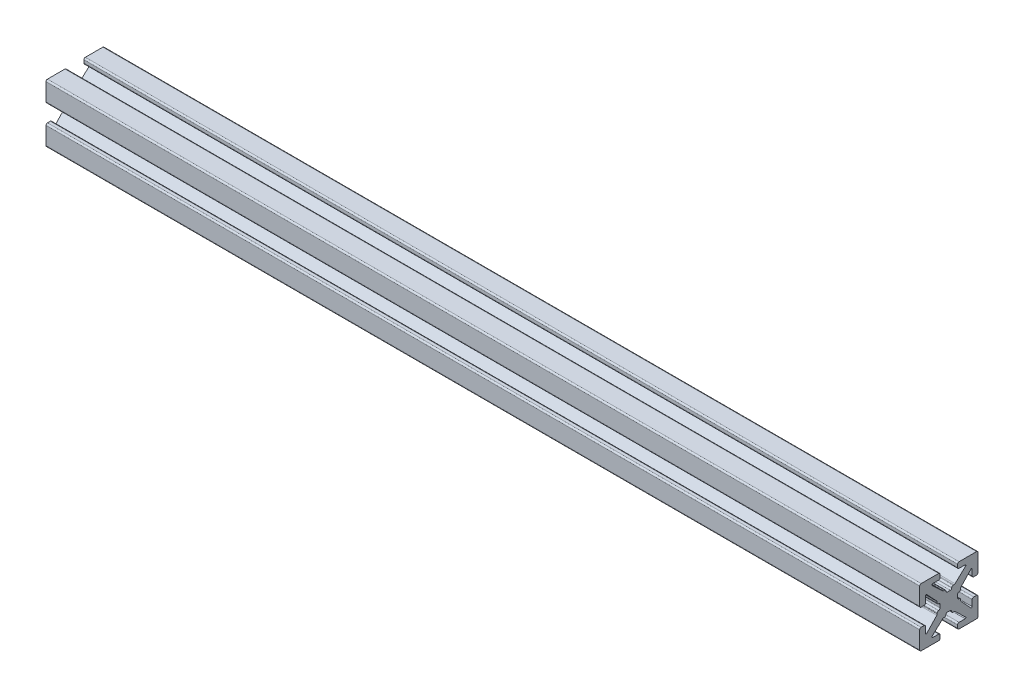
from build123d import *

# Parameters (mm, degrees)
BOSS_EXTRU_1_DEPTH = 150


with BuildPart() as part:
    # Sketch1 → Boss.-Extru.1 (new body)
    with BuildSketch(Plane(origin=(0, 0, 0), x_dir=(0, 0, -1), z_dir=(1, 0, 0))):
        with BuildLine():
            Line((-0.2413, 1.4986), (0.2413, 1.4986))
            ThreePointArc((0.2413, 1.4986), (0.420905122, 1.572994878), (0.4953, 1.7526))
            ThreePointArc((0.4953, 1.7526), (0.569694878, 1.932205122), (0.7493, 2.0066))
            Line((0.7493, 2.0066), (0.889923986, 2.0066))
            ThreePointArc((0.889923986, 2.0066), (0.983516259, 2.024471886), (1.063937899, 2.075572548))
            Line((1.063937899, 2.075572548), (2.890793, 3.793686274))
            ThreePointArc((2.890793, 3.793686274), (2.921850101, 3.932996137), (2.803786044, 4.0132))
            Line((2.803786044, 4.0132), (1.7526, 4.0132))
            ThreePointArc((1.7526, 4.0132), (1.572994878, 4.087594878), (1.4986, 4.2672))
            Line((1.4986, 4.2672), (1.4986, 4.7498))
            ThreePointArc((1.4986, 4.7498), (1.572994878, 4.929405122), (1.7526, 5.0038))
            Line((1.7526, 5.0038), (4.7498, 5.0038))
            ThreePointArc((4.7498, 5.0038), (4.929405122, 4.929405122), (5.0038, 4.7498))
            Line((5.0038, 4.7498), (5.0038, 1.7526))
            ThreePointArc((5.0038, 1.7526), (4.929405122, 1.572994878), (4.7498, 1.4986))
            Line((4.7498, 1.4986), (4.2672, 1.4986))
            ThreePointArc((4.2672, 1.4986), (4.087594878, 1.572994878), (4.0132, 1.7526))
            Line((4.0132, 1.7526), (4.0132, 2.803786044))
            ThreePointArc((4.0132, 2.803786044), (3.932996137, 2.921850101), (3.793686274, 2.890793))
            Line((3.793686274, 2.890793), (2.075572548, 1.063937899))
            ThreePointArc((2.075572548, 1.063937899), (2.024471886, 0.983516259), (2.0066, 0.889923986))
            Line((2.0066, 0.889923986), (2.0066, 0.7493))
            ThreePointArc((2.0066, 0.7493), (1.932205122, 0.569694878), (1.7526, 0.4953))
            ThreePointArc((1.7526, 0.4953), (1.572994878, 0.420905122), (1.4986, 0.2413))
            Line((1.4986, 0.2413), (1.4986, -0.2413))
            ThreePointArc((1.4986, -0.2413), (1.572994878, -0.420905122), (1.7526, -0.4953))
            ThreePointArc((1.7526, -0.4953), (1.932205122, -0.569694878), (2.0066, -0.7493))
            Line((2.0066, -0.7493), (2.0066, -0.889923986))
            ThreePointArc((2.0066, -0.889923986), (2.024471886, -0.983516259), (2.075572548, -1.063937899))
            Line((2.075572548, -1.063937899), (3.793686274, -2.890793))
            ThreePointArc((3.793686274, -2.890793), (3.932996137, -2.921850101), (4.0132, -2.803786044))
            Line((4.0132, -2.803786044), (4.0132, -1.7526))
            ThreePointArc((4.0132, -1.7526), (4.087594878, -1.572994878), (4.2672, -1.4986))
            Line((4.2672, -1.4986), (4.7498, -1.4986))
            ThreePointArc((4.7498, -1.4986), (4.929405122, -1.572994878), (5.0038, -1.7526))
            Line((5.0038, -1.7526), (5.0038, -4.7498))
            ThreePointArc((5.0038, -4.7498), (4.929405122, -4.929405122), (4.7498, -5.0038))
            Line((4.7498, -5.0038), (1.7526, -5.0038))
            ThreePointArc((1.7526, -5.0038), (1.572994878, -4.929405122), (1.4986, -4.7498))
            Line((1.4986, -4.7498), (1.4986, -4.2672))
            ThreePointArc((1.4986, -4.2672), (1.572994878, -4.087594878), (1.7526, -4.0132))
            Line((1.7526, -4.0132), (2.803786044, -4.0132))
            ThreePointArc((2.803786044, -4.0132), (2.921850101, -3.932996137), (2.890793, -3.793686274))
            Line((2.890793, -3.793686274), (1.063937899, -2.075572548))
            ThreePointArc((1.063937899, -2.075572548), (0.983516259, -2.024471886), (0.889923986, -2.0066))
            Line((0.889923986, -2.0066), (0.7493, -2.0066))
            ThreePointArc((0.7493, -2.0066), (0.569694878, -1.932205122), (0.4953, -1.7526))
            ThreePointArc((0.4953, -1.7526), (0.420905122, -1.572994878), (0.2413, -1.4986))
            Line((0.2413, -1.4986), (-0.2413, -1.4986))
            ThreePointArc((-0.2413, -1.4986), (-0.420905122, -1.572994878), (-0.4953, -1.7526))
            ThreePointArc((-0.4953, -1.7526), (-0.569694878, -1.932205122), (-0.7493, -2.0066))
            Line((-0.7493, -2.0066), (-0.889923986, -2.0066))
            ThreePointArc((-0.889923986, -2.0066), (-0.983516259, -2.024471886), (-1.063937899, -2.075572548))
            Line((-1.063937899, -2.075572548), (-2.890793, -3.793686274))
            ThreePointArc((-2.890793, -3.793686274), (-2.921850101, -3.932996137), (-2.803786044, -4.0132))
            Line((-2.803786044, -4.0132), (-1.7526, -4.0132))
            ThreePointArc((-1.7526, -4.0132), (-1.572994878, -4.087594878), (-1.4986, -4.2672))
            Line((-1.4986, -4.2672), (-1.4986, -4.7498))
            ThreePointArc((-1.4986, -4.7498), (-1.572994878, -4.929405122), (-1.7526, -5.0038))
            Line((-1.7526, -5.0038), (-4.7498, -5.0038))
            ThreePointArc((-4.7498, -5.0038), (-4.929405122, -4.929405122), (-5.0038, -4.7498))
            Line((-5.0038, -4.7498), (-5.0038, -1.7526))
            ThreePointArc((-5.0038, -1.7526), (-4.929405122, -1.572994878), (-4.7498, -1.4986))
            Line((-4.7498, -1.4986), (-4.2672, -1.4986))
            ThreePointArc((-4.2672, -1.4986), (-4.087594878, -1.572994878), (-4.0132, -1.7526))
            Line((-4.0132, -1.7526), (-4.0132, -2.803786044))
            ThreePointArc((-4.0132, -2.803786044), (-3.932996137, -2.921850101), (-3.793686274, -2.890793))
            Line((-3.793686274, -2.890793), (-2.075572548, -1.063937899))
            ThreePointArc((-2.075572548, -1.063937899), (-2.024471886, -0.983516259), (-2.0066, -0.889923986))
            Line((-2.0066, -0.889923986), (-2.0066, -0.7493))
            ThreePointArc((-2.0066, -0.7493), (-1.932205122, -0.569694878), (-1.7526, -0.4953))
            ThreePointArc((-1.7526, -0.4953), (-1.572994878, -0.420905122), (-1.4986, -0.2413))
            Line((-1.4986, -0.2413), (-1.4986, 0.2413))
            ThreePointArc((-1.4986, 0.2413), (-1.572994878, 0.420905122), (-1.7526, 0.4953))
            ThreePointArc((-1.7526, 0.4953), (-1.932205122, 0.569694878), (-2.0066, 0.7493))
            Line((-2.0066, 0.7493), (-2.0066, 0.889923986))
            ThreePointArc((-2.0066, 0.889923986), (-2.024471886, 0.983516259), (-2.075572548, 1.063937899))
            Line((-2.075572548, 1.063937899), (-3.793686274, 2.890793))
            ThreePointArc((-3.793686274, 2.890793), (-3.932996137, 2.921850101), (-4.0132, 2.803786044))
            Line((-4.0132, 2.803786044), (-4.0132, 1.7526))
            ThreePointArc((-4.0132, 1.7526), (-4.087594878, 1.572994878), (-4.2672, 1.4986))
            Line((-4.2672, 1.4986), (-4.7498, 1.4986))
            ThreePointArc((-4.7498, 1.4986), (-4.929405122, 1.572994878), (-5.0038, 1.7526))
            Line((-5.0038, 1.7526), (-5.0038, 4.7498))
            ThreePointArc((-5.0038, 4.7498), (-4.929405122, 4.929405122), (-4.7498, 5.0038))
            Line((-4.7498, 5.0038), (-1.7526, 5.0038))
            ThreePointArc((-1.7526, 5.0038), (-1.572994878, 4.929405122), (-1.4986, 4.7498))
            Line((-1.4986, 4.7498), (-1.4986, 4.2672))
            ThreePointArc((-1.4986, 4.2672), (-1.572994878, 4.087594878), (-1.7526, 4.0132))
            Line((-1.7526, 4.0132), (-2.803786044, 4.0132))
            ThreePointArc((-2.803786044, 4.0132), (-2.921850101, 3.932996137), (-2.890793, 3.793686274))
            Line((-2.890793, 3.793686274), (-1.063937899, 2.075572548))
            ThreePointArc((-1.063937899, 2.075572548), (-0.983516259, 2.024471886), (-0.889923986, 2.0066))
            Line((-0.889923986, 2.0066), (-0.7493, 2.0066))
            ThreePointArc((-0.7493, 2.0066), (-0.569694878, 1.932205122), (-0.4953, 1.7526))
            ThreePointArc((-0.4953, 1.7526), (-0.420905122, 1.572994878), (-0.2413, 1.4986))
        make_face()
    extrude(amount=BOSS_EXTRU_1_DEPTH)


solid = part.part
